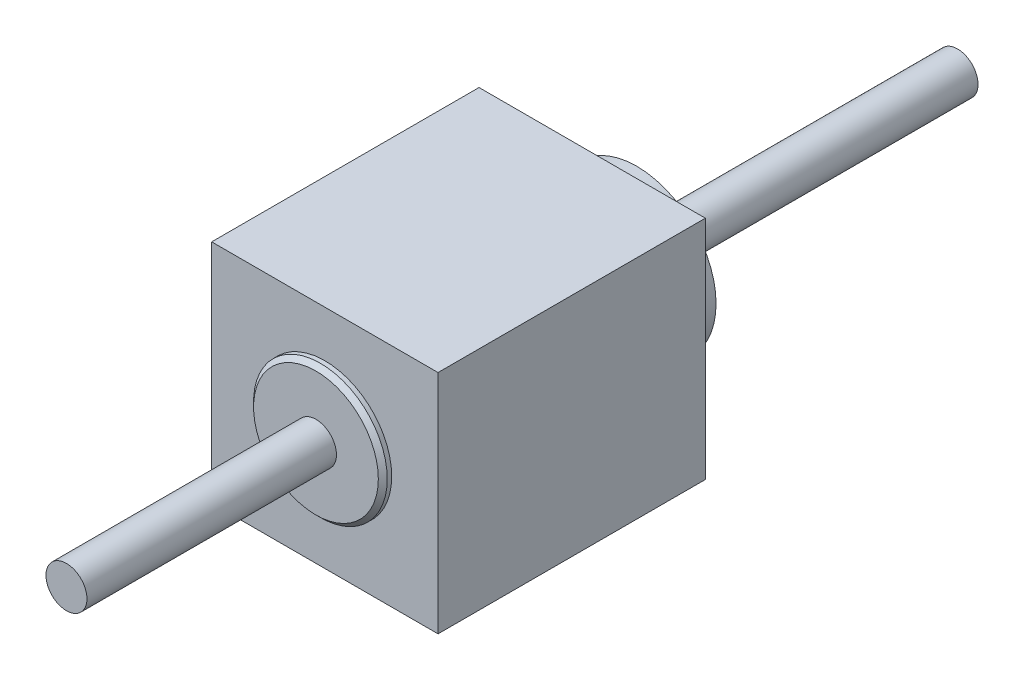
from build123d import *

# Parameters (mm, degrees)
SKETCH1_W           = 2.54
SKETCH1_H           = 2.54
BOSS_EXTRUDE1_DEPTH = 3
SKETCH2_R           = 0.23
BOSS_EXTRUDE2_DEPTH = 4.1
SKETCH3_R           = 0.89
BOSS_EXTRUDE3_DEPTH = 0.5
SKETCH4_R           = 0.23
BOSS_EXTRUDE4_DEPTH = 2.9
SKETCH5_R           = 0.75
BOSS_EXTRUDE5_DEPTH = 0.1
CHAMFER1_SIZE       = 0.05


with BuildPart() as part:
    # Sketch1 → Boss-Extrude1 (new body)
    with BuildSketch(Plane.XY):
        Rectangle(SKETCH1_W, SKETCH1_H)
    extrude(amount=BOSS_EXTRUDE1_DEPTH)

    # Sketch2 → Boss-Extrude2 (add)
    with BuildSketch(Plane(origin=(0, 0, 0), x_dir=(-1, 0, 0), z_dir=(0, 0, -1))):
        Circle(SKETCH2_R)
    extrude(amount=BOSS_EXTRUDE2_DEPTH)

    # Sketch3 → Boss-Extrude3 (add)
    with BuildSketch(Plane(origin=(0, 0, 0), x_dir=(-1, 0, 0), z_dir=(0, 0, -1))):
        Circle(SKETCH3_R)
    extrude(amount=BOSS_EXTRUDE3_DEPTH)

    # Sketch4 → Boss-Extrude4 (add)
    with BuildSketch(Plane.XY.offset(3)):
        Circle(SKETCH4_R)
    extrude(amount=BOSS_EXTRUDE4_DEPTH)

    # Sketch5 → Boss-Extrude5 (add)
    with BuildSketch(Plane.XY.offset(3)):
        Circle(SKETCH5_R)
    extrude(amount=BOSS_EXTRUDE5_DEPTH)

    # Chamfer1
    chamfer1_edges = [part.edges().sort_by_distance(p)[0] for p in [
        (-0.75, 0, 3.1),
    ]]
    chamfer(chamfer1_edges, length=CHAMFER1_SIZE)


solid = part.part
